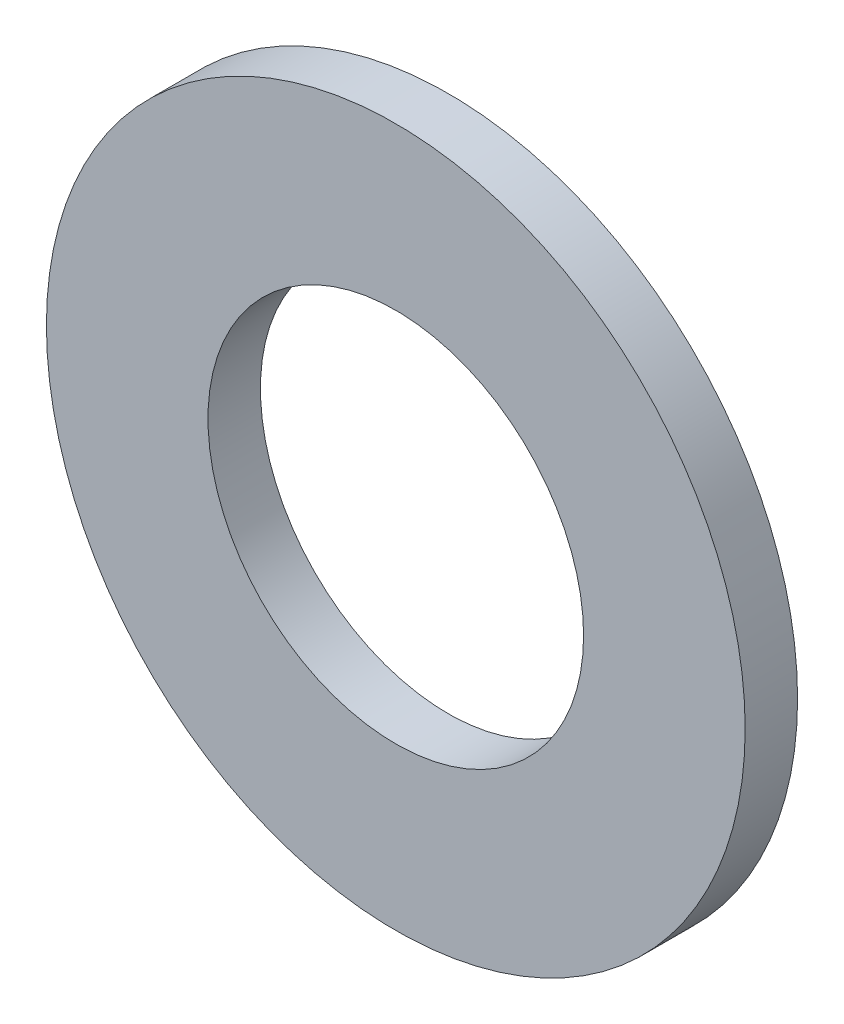
from build123d import *

# Parameters (mm, degrees)
SKETCH3_R                = 4
SKETCH3_R_2              = 2.15
BOSS_EXTRUDE1_DEPTH      = 0.3
BOSS_EXTRUDE1_DEPTH_BACK = 0.3


with BuildPart() as part:
    # Sketch3 → Boss-Extrude1 (new body, two sides)
    with BuildSketch(Plane.XY) as boss_extrude1_sk:
        Circle(SKETCH3_R)
        Circle(SKETCH3_R_2, mode=Mode.SUBTRACT)
    extrude(amount=BOSS_EXTRUDE1_DEPTH)
    extrude(boss_extrude1_sk.sketch, amount=-BOSS_EXTRUDE1_DEPTH_BACK)


solid = part.part
